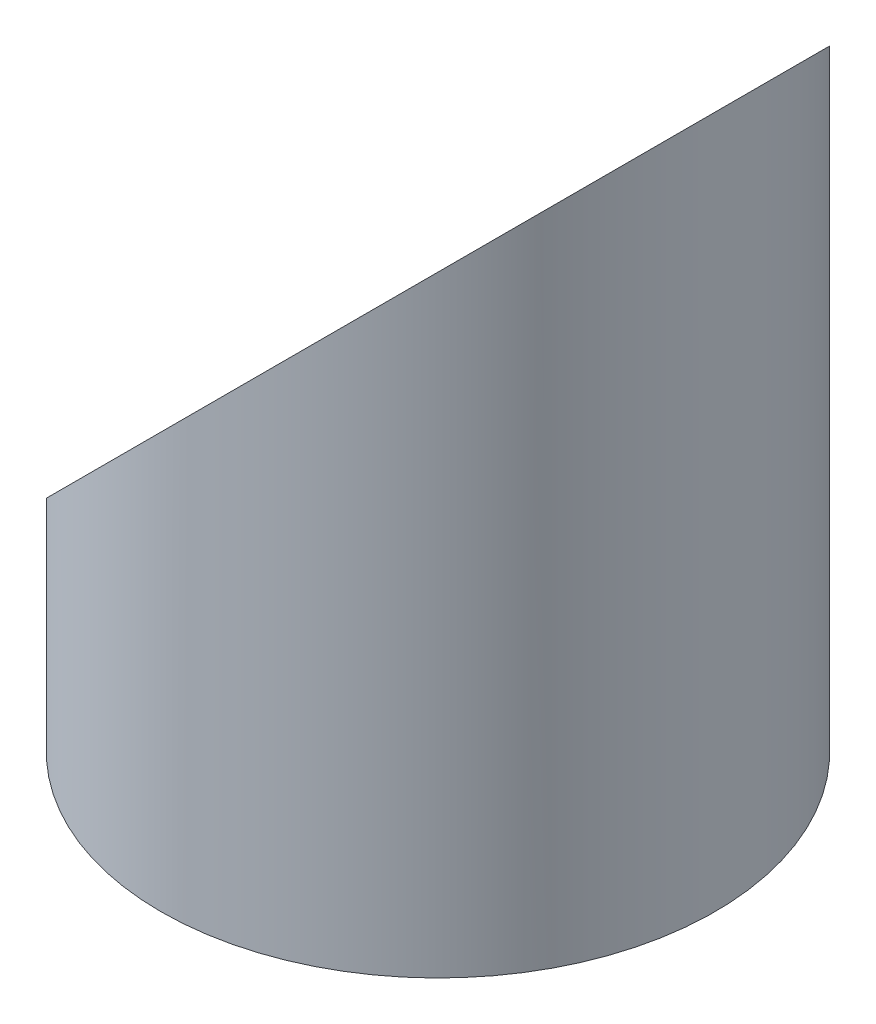
from build123d import *

# Parameters (mm, degrees)
SKETCH1_R               = 40
BOSS_EXTRUDE1_DEPTH     = 100
CUT_EXTRUDE1_DEPTH      = 41
CUT_EXTRUDE1_DEPTH_BACK = 41


with BuildPart() as part:
    # Sketch1 → Boss-Extrude1 (new body)
    with BuildSketch(Plane(origin=(0, 0, 0), x_dir=(1, 0, 0), z_dir=(0, 1, 0))):
        Circle(SKETCH1_R)
        Polygon((0, -20), (-20, 0), (0, 20), (20, 0), align=None, mode=Mode.SUBTRACT)
    extrude(amount=BOSS_EXTRUDE1_DEPTH)

    # Sketch2 → Cut-Extrude1 (cut, two sides)
    with BuildSketch(Plane.XY) as cut_extrude1_sk:
        Polygon((-40, 20), (40, 100), (-40, 100), align=None)
    extrude(amount=CUT_EXTRUDE1_DEPTH, mode=Mode.SUBTRACT)
    extrude(cut_extrude1_sk.sketch, amount=-CUT_EXTRUDE1_DEPTH_BACK, mode=Mode.SUBTRACT)


solid = part.part
